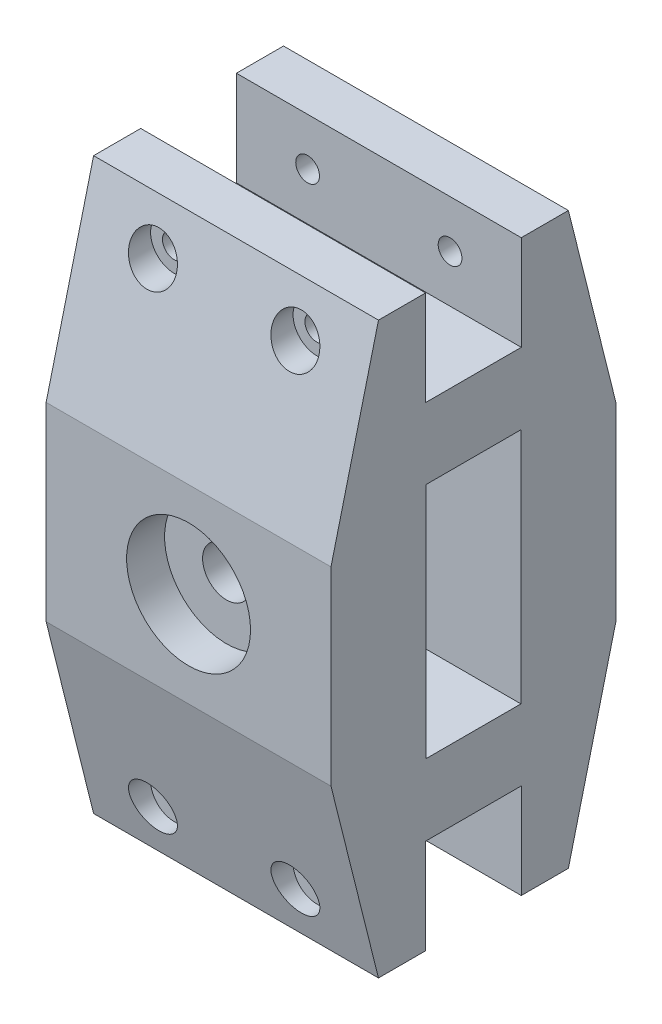
from build123d import *

# Parameters (mm, degrees)
BOSS_EXTRUDE1_DEPTH = 60
SKETCH3_R           = 5.05
CUT_EXTRUDE1_DEPTH  = 70
SKETCH4_R           = 13.05
CUT_EXTRUDE2_DEPTH  = 8
SKETCH5_R           = 2.5
CUT_EXTRUDE3_DEPTH  = 61
SKETCH6_R           = 5
CUT_EXTRUDE4_DEPTH  = 12
SKETCH7_W           = 20
SKETCH7_H           = 50
CUT_EXTRUDE5_DEPTH  = 81


with BuildPart() as part:
    # Sketch2 → Boss-Extrude1 (new body)
    with BuildSketch(Plane(origin=(0, 0, 0), x_dir=(0, 0, -1), z_dir=(1, 0, 0))):
        Polygon((0, 40), (10, 0), (19.925, 0), (19.925, 20), (40.075, 20), (40.075, 0), (50, 0), (60, 40), (60, 80), (50, 120), (40.075, 120), (40.075, 100), (19.925, 100), (19.925, 120), (10, 120), (0, 80), align=None)
    extrude(amount=BOSS_EXTRUDE1_DEPTH)

    # Sketch3 → Cut-Extrude1 (cut)
    with BuildSketch(Plane.XY):
        with Locations((30, 60)):
            Circle(SKETCH3_R)
    extrude(amount=-CUT_EXTRUDE1_DEPTH, mode=Mode.SUBTRACT)

    # Sketch4 → Cut-Extrude2 (cut)
    with BuildSketch(Plane.XY):
        with Locations((30, 60)):
            Circle(SKETCH4_R)
    cut_extrude2 = extrude(amount=-CUT_EXTRUDE2_DEPTH, mode=Mode.SUBTRACT)

    # Mirror1: Cut-Extrude2 across plane
    add(cut_extrude2.mirror(Plane.XY.offset(-30)), mode=Mode.SUBTRACT)

    # Sketch5 → Cut-Extrude3 (cut, through all)
    with BuildSketch(Plane.XY):
        with Locations((45, 110)):
            Circle(SKETCH5_R)
        with Locations((15, 110)):
            Circle(SKETCH5_R)
        with Locations((45, 10)):
            Circle(SKETCH5_R)
        with Locations((15, 10)):
            Circle(SKETCH5_R)
    extrude(amount=-CUT_EXTRUDE3_DEPTH, mode=Mode.SUBTRACT)

    # Sketch6 → Cut-Extrude4 (cut)
    with BuildSketch(Plane.XY):
        with Locations((45, 110)):
            Circle(SKETCH6_R)
        with Locations((15, 110)):
            Circle(SKETCH6_R)
        with Locations((15, 10)):
            Circle(SKETCH6_R)
        with Locations((45, 10)):
            Circle(SKETCH6_R)
    cut_extrude4 = extrude(amount=-CUT_EXTRUDE4_DEPTH, mode=Mode.SUBTRACT)

    # Mirror2: Cut-Extrude4 across plane
    add(cut_extrude4.mirror(Plane.XY.offset(-30)), mode=Mode.SUBTRACT)

    # Sketch7 → Cut-Extrude5 (cut)
    with BuildSketch(Plane(origin=(60, 0, 0), x_dir=(0, 0, -1), z_dir=(1, 0, 0))):
        with Locations((30, 60)):
            Rectangle(SKETCH7_W, SKETCH7_H)
    extrude(amount=-CUT_EXTRUDE5_DEPTH, mode=Mode.SUBTRACT)


solid = part.part
